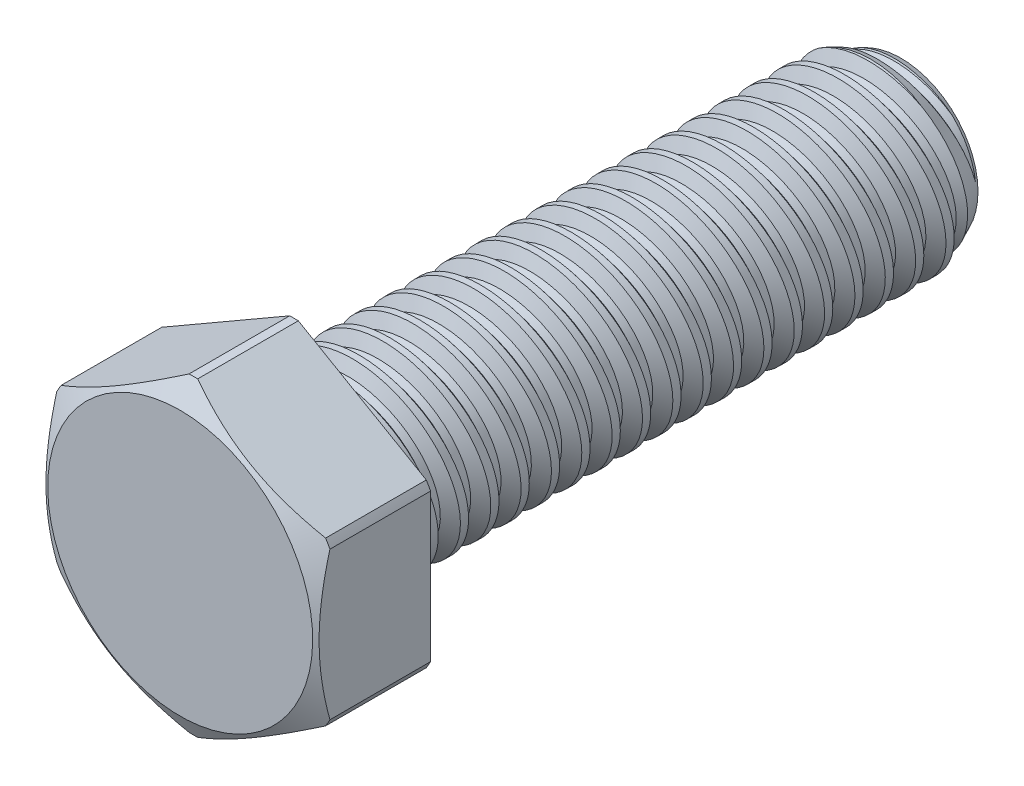
from build123d import *

# Parameters (mm, degrees)
SKETCH1_W            = 31.75
SKETCH1_H            = 4.7625
LPATTERN1_COUNT      = 2
LPATTERN1_PITCH      = 1.5875
LPATTERN1_COUNT_DIR2 = 20
LPATTERN1_PITCH_DIR2 = 1.5875
EXTRUDE1_DEPTH       = 5.953125


with BuildPart() as part:
    # Sketch1 → Revolve1 (revolve)
    with BuildSketch(Plane(origin=(0, 0, 0), x_dir=(0, 0, -1), z_dir=(1, 0, 0)), mode=Mode.PRIVATE) as revolve1_sk:
        with Locations((0, 2.38125)):
            Rectangle(SKETCH1_W, SKETCH1_H)
    revolve(revolve1_sk.sketch.rotate(Axis((0, 0, 15.875), (0, 0, 1)), 124.561991019), axis=Axis((0, 0, 15.875), (0, 0, 1)))

    # Sketch2 → Cut-Revolve1 (revolve, cut)
    with BuildSketch(Plane(origin=(0, 0, 0), x_dir=(0, 0, -1), z_dir=(1, 0, 0)), mode=Mode.PRIVATE) as cut_revolve1_sk:
        Polygon((-14.309099646, 5.023483392), (-15.679262456, 4.795122924), (-15.04865719, 4.029111805), (-14.657182102, 4.094357653), align=None)
    cut_revolve1 = revolve(cut_revolve1_sk.sketch.rotate(Axis((0, -0.28317269, 15.875), (0, 0.164398987, -0.986393924)), 180), axis=Axis((0, -0.28317269, 15.875), (0, 0.164398987, -0.986393924)), mode=Mode.SUBTRACT)

    # Sketch3 → Cut-Revolve2 (revolve, cut)
    with BuildSketch(Plane(origin=(0, 0, 0), x_dir=(0, 0, -1), z_dir=(1, 0, 0)), mode=Mode.PRIVATE) as cut_revolve2_sk:
        Polygon((14.302243941, 4.7625), (15.875, 4.029111805), (15.875, 4.7625), align=None)
    revolve(cut_revolve2_sk.sketch.rotate(Axis((0, 0, 0), (0, 0, -1)), 235.438008981), axis=Axis((0, 0, 0), (0, 0, -1)), mode=Mode.SUBTRACT)

    # LPattern1: Cut-Revolve1 2 × 20
    with Locations(*[Vector(0, 0, 1) * (i * LPATTERN1_PITCH) + Vector(0, 0, -1) * (j * LPATTERN1_PITCH_DIR2) for i in range(LPATTERN1_COUNT) for j in range(LPATTERN1_COUNT_DIR2) if (i, j) != (0, 0)]):
        add(cut_revolve1, mode=Mode.SUBTRACT)

    # Sketch5 → Extrude1 (add)
    with BuildSketch(Plane.XY.offset(15.875)):
        Polygon((0, 8.248891971), (-7.14375, 4.124445986), (-7.14375, -4.124445986), (0, -8.248891971), (7.14375, -4.124445986), (7.14375, 4.124445986), align=None)
    extrude(amount=EXTRUDE1_DEPTH)

    # Sketch6 → Cut-Revolve3 (revolve, cut)
    with BuildSketch(Plane(origin=(0, 0, 0), x_dir=(0, 0, -1), z_dir=(1, 0, 0)), mode=Mode.PRIVATE) as cut_revolve3_sk:
        Polygon((-21.828125, 6.9294375), (-21.13966109, 8.121891971), (-15.875, 8.121891971), (-15.875, 8.629891971), (-21.828125, 8.629891971), align=None)
    revolve(cut_revolve3_sk.sketch.rotate(Axis((0, 0, 0), (0, 0, 1)), 124.561991019), axis=Axis((0, 0, 0), (0, 0, 1)), mode=Mode.SUBTRACT)


solid = part.part
